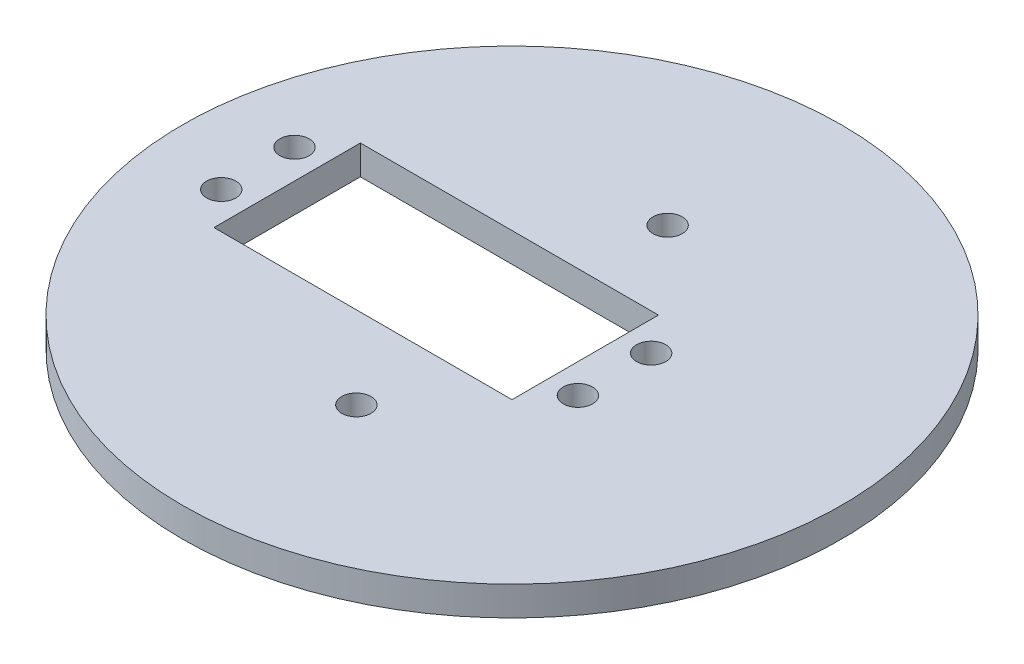
from build123d import *

# Parameters (mm, degrees)
SCHIZZO1_R                   = 45
ESTRUSIONE_ESTRUSIONE1_DEPTH = 2
CROQUIS1_R                   = 2
CROQUIS1_W                   = 40.7
CROQUIS1_H                   = 20
CORTAR_EXTRUIR1_DEPTH        = 10


with BuildPart() as part:
    # Schizzo1 → Estrusione-Estrusione1 (new body, symmetric)
    with BuildSketch(Plane(origin=(0, 0, 0), x_dir=(1, 0, 0), z_dir=(0, 1, 0))):
        Circle(SCHIZZO1_R)
    extrude(amount=ESTRUSIONE_ESTRUSIONE1_DEPTH, both=True)

    # Croquis1 → Cortar-Extruir1 (cut)
    with BuildSketch(Plane(origin=(0, 2, 0), x_dir=(1, 0, 0), z_dir=(0, 1, 0))):
        with Locations((-34.7, 5)):
            Circle(CROQUIS1_R)
        with Locations((-34.7, -5)):
            Circle(CROQUIS1_R)
        with Locations((0, -21.25)):
            Circle(CROQUIS1_R)
        with Locations((0, 21.25)):
            Circle(CROQUIS1_R)
        with Locations((14, 5)):
            Circle(CROQUIS1_R)
        with Locations((14, -5)):
            Circle(CROQUIS1_R)
        with Locations((-10.35, 0)):
            Rectangle(CROQUIS1_W, CROQUIS1_H)
    extrude(amount=-CORTAR_EXTRUIR1_DEPTH, mode=Mode.SUBTRACT)


solid = part.part
